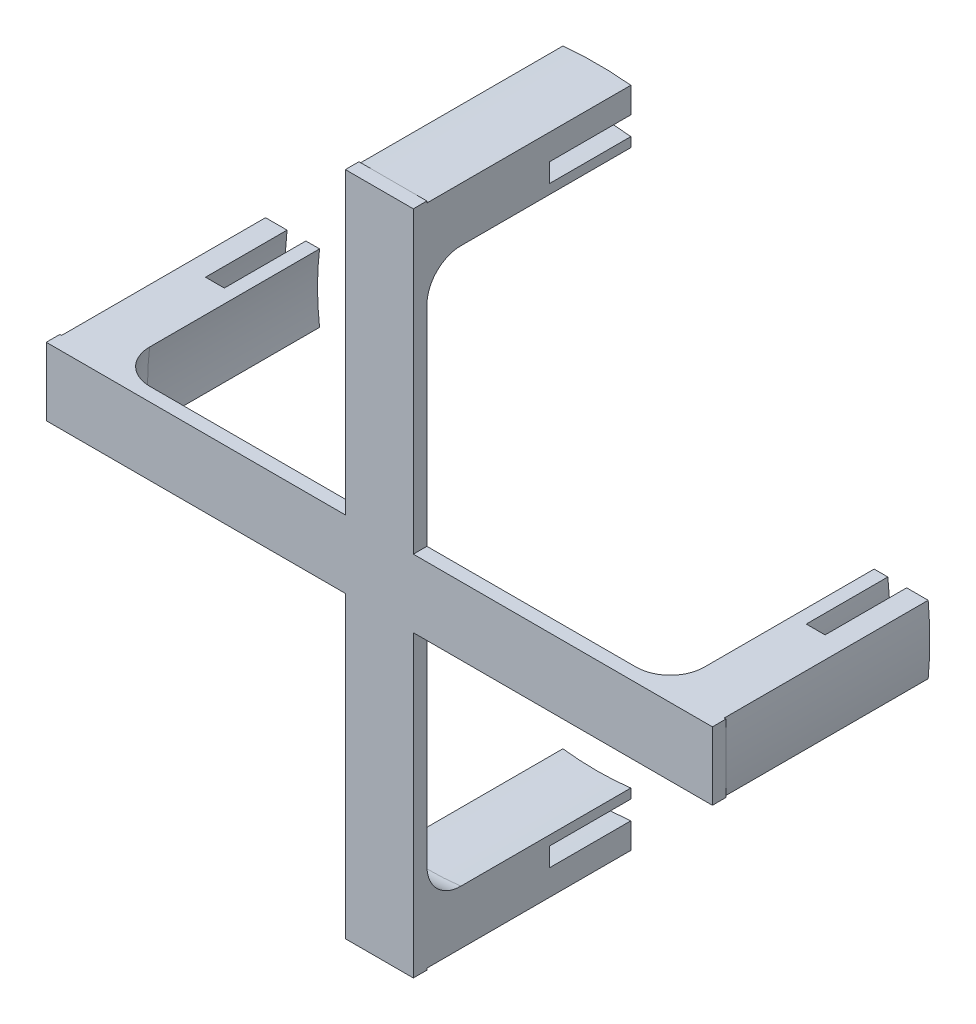
from build123d import *

# Parameters (mm, degrees)
SKETCH1_W           = 10
SKETCH1_H           = 10
SKETCH1_W_2         = 44
SKETCH1_H_2         = 44
BOSS_EXTRUDE1_DEPTH = 2
BOSS_EXTRUDE2_DEPTH = 30
CUT_EXTRUDE1_DEPTH  = 12
CUT_EXTRUDE2_DEPTH  = 12
FILLET1_R           = 5


with BuildPart() as part:
    # Sketch1 → Boss-Extrude1 (new body)
    with BuildSketch(Plane.XY):
        Rectangle(SKETCH1_W, SKETCH1_H)
        with Locations((-27, 0)):
            Rectangle(SKETCH1_W_2, SKETCH1_H)
        with Locations((0, 27)):
            Rectangle(SKETCH1_W, SKETCH1_H_2)
        with Locations((27, 0)):
            Rectangle(SKETCH1_W_2, SKETCH1_H)
        with Locations((0, -27)):
            Rectangle(SKETCH1_W, SKETCH1_H_2)
    extrude(amount=BOSS_EXTRUDE1_DEPTH)

    # Sketch3 → Boss-Extrude2 (add)
    with BuildSketch(Plane(origin=(0, 0, 0), x_dir=(-1, 0, 0), z_dir=(0, 0, -1))):
        with BuildLine():
            Line((-48.744230428, 5), (-40.794730052, 5))
            ThreePointArc((-40.794730052, 5), (-41.1, 0), (-40.794730052, -5))
            Line((-40.794730052, -5), (-48.744230428, -5))
            ThreePointArc((-48.744230428, -5), (-49, 0), (-48.744230428, 5))
        make_face()
        with BuildLine():
            Line((5, 48.744230428), (5, 40.794730052))
            ThreePointArc((5, 40.794730052), (0, 41.1), (-5, 40.794730052))
            Line((-5, 40.794730052), (-5, 48.744230428))
            ThreePointArc((-5, 48.744230428), (0, 49), (5, 48.744230428))
        make_face()
        with BuildLine():
            Line((48.744230428, -5), (40.794730052, -5))
            ThreePointArc((40.794730052, -5), (41.1, 0), (40.794730052, 5))
            Line((40.794730052, 5), (48.744230428, 5))
            ThreePointArc((48.744230428, 5), (49, 0), (48.744230428, -5))
        make_face()
        with BuildLine():
            Line((-5, -48.744230428), (-5, -40.794730052))
            ThreePointArc((-5, -40.794730052), (0, -41.1), (5, -40.794730052))
            Line((5, -40.794730052), (5, -48.744230428))
            ThreePointArc((5, -48.744230428), (0, -49), (-5, -48.744230428))
        make_face()
    extrude(amount=BOSS_EXTRUDE2_DEPTH)

    # Sketch4 → Cut-Extrude1 (cut)
    with BuildSketch(Plane(origin=(0, 0, -30), x_dir=(-1, 0, 0), z_dir=(0, 0, -1))):
        with BuildLine():
            Line((-11.10557259, -44.484702511), (-11.461711595, -41.548034458))
            ThreePointArc((-11.461711595, -41.548034458), (-43.096967164, -0.511293704), (-12.444181806, 41.264419773))
            Line((-12.444181806, 41.264419773), (-14.129590932, 43.618541471))
            ThreePointArc((-14.129590932, 43.618541471), (-45.823015718, -1.572809738), (-11.10557259, -44.484702511))
        make_face()
        with BuildLine():
            Line((12.001150898, -44.251495762), (13.254659766, -41.011266677))
            ThreePointArc((13.254659766, -41.011266677), (43.094432914, 0.692713402), (11.929696672, 41.416087905))
            Line((11.929696672, 41.416087905), (17.322221173, 42.451892227))
            ThreePointArc((17.322221173, 42.451892227), (45.76389854, -2.80857445), (12.001150898, -44.251495762))
        make_face()
    extrude(amount=-CUT_EXTRUDE1_DEPTH, mode=Mode.SUBTRACT)

    # Sketch5 → Cut-Extrude2 (cut)
    with BuildSketch(Plane(origin=(0, 0, -30), x_dir=(-1, 0, 0), z_dir=(0, 0, -1))):
        with BuildLine():
            Line((-42.028433613, 16.76822197), (-39.816299645, 14.863118199))
            ThreePointArc((-39.816299645, 14.863118199), (-0.915555868, 42.490137179), (39.139115264, 16.564409328))
            Line((39.139115264, 16.564409328), (42.109177665, 16.564409328))
            ThreePointArc((42.109177665, 16.564409328), (0.109612038, 45.24986724), (-42.028433613, 16.76822197))
        make_face()
        with BuildLine():
            Line((-42.268216712, -16.154267422), (-39.699430061, -15.172516364))
            ThreePointArc((-39.699430061, -15.172516364), (-1.394243302, -42.477124263), (38.619024806, -17.743193711))
            Line((38.619024806, -17.743193711), (40.007756731, -21.141000481))
            ThreePointArc((40.007756731, -21.141000481), (-2.737571274, -45.167114182), (-42.268216712, -16.154267422))
        make_face()
    extrude(amount=-CUT_EXTRUDE2_DEPTH, mode=Mode.SUBTRACT)

    # Fillet1
    fillet1_edges = [part.edges().sort_by_distance(p)[0] for p in [
        (41.1, 0, 0),
        (0, 41.1, 0),
        (-41.1, 0, 0),
        (0, -41.1, 0),
    ]]
    fillet(fillet1_edges, radius=FILLET1_R)


solid = part.part
